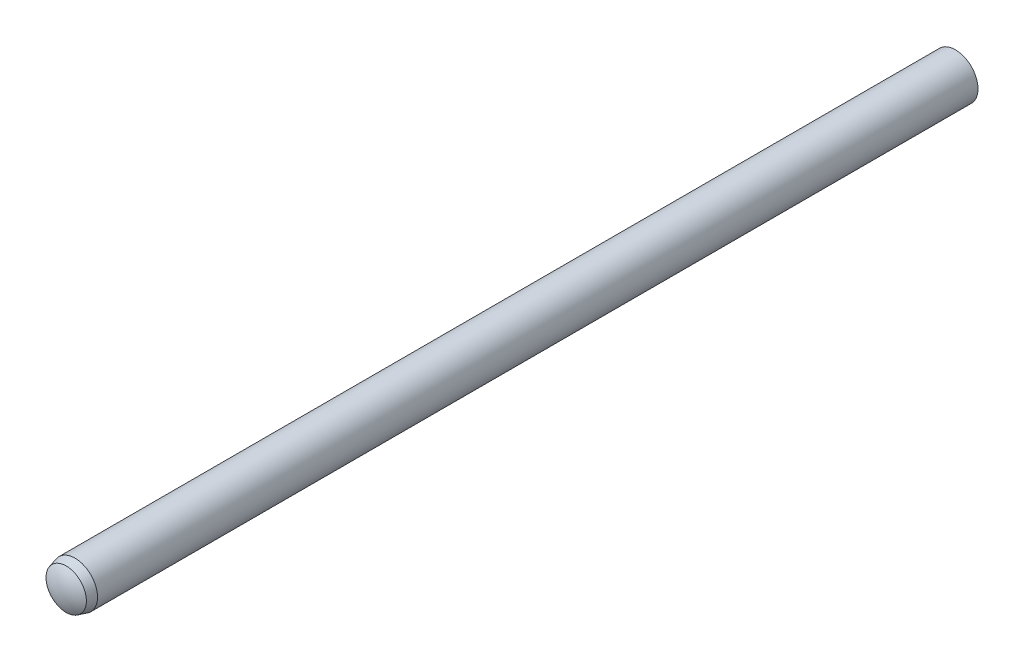
from build123d import *


with BuildPart() as part:
    # Sketch3 → Revolve1 (revolve)
    with BuildSketch(Plane(origin=(0, 0, 0), x_dir=(0, 0, -1), z_dir=(1, 0, 0))):
        with BuildLine():
            Line((-40, 0), (40, 0))
            ThreePointArc((40, 0), (39.846768836, 1.044030651), (39.4, 2))
            Line((39.4, 2), (-38.7, 2))
            Line((-38.7, 2), (-39.48, 1.79099963))
            ThreePointArc((-39.48, 1.79099963), (-39.867370053, 0.932480519), (-40, 0))
        make_face()
    revolve(axis=Axis((0, 0, 40), (0, 0, -1)))


solid = part.part
